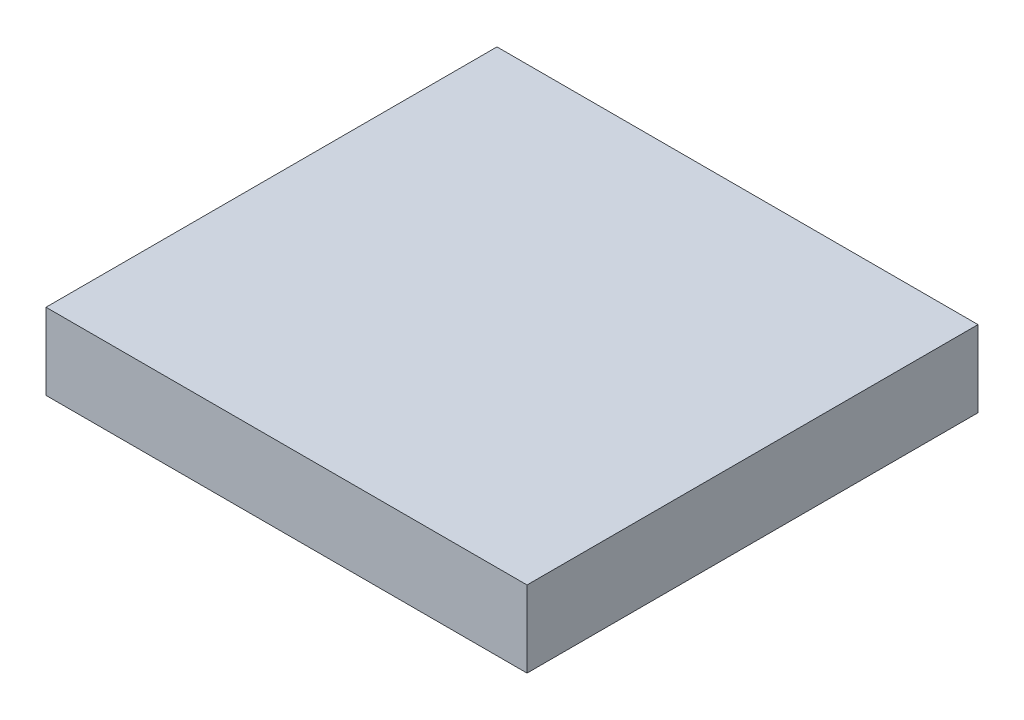
from build123d import *

# Parameters (mm, degrees)
SKETCH1_W           = 96
SKETCH1_H           = 90
BOSS_EXTRUDE1_DEPTH = 15.24


with BuildPart() as part:
    # Sketch1 → Boss-Extrude1 (new body)
    with BuildSketch(Plane(origin=(0, 0, 0), x_dir=(1, 0, 0), z_dir=(0, 1, 0))):
        with Locations((48, 45)):
            Rectangle(SKETCH1_W, SKETCH1_H)
    extrude(amount=BOSS_EXTRUDE1_DEPTH)


solid = part.part
